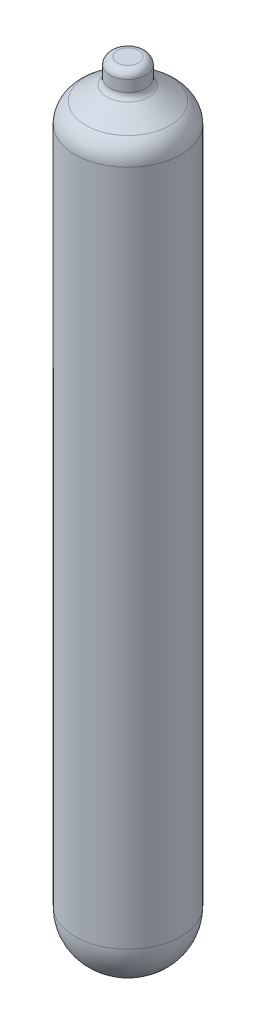
from build123d import *


with BuildPart() as part:
    # Эскиз1 → Повернуть1 (revolve)
    with BuildSketch(Plane.XY):
        with BuildLine():
            Line((0, 0), (10, 0))
            ThreePointArc((10, 0), (80.710678119, 29.289321881), (110, 100))
            Line((110, 100), (110, 1507.617384372))
            ThreePointArc((110, 1507.617384372), (104.090062317, 1531.198444671), (87.757343806, 1549.205001097))
            Line((87.757343806, 1549.205001097), (43.961595612, 1578.436145741))
            ThreePointArc((43.961595612, 1578.436145741), (39.061780059, 1583.838112668), (37.288798754, 1590.912430758))
            Line((37.288798754, 1590.912430758), (37.288798754, 1614.158761672))
            ThreePointArc((37.288798754, 1614.158761672), (32.895400472, 1624.76536339), (22.288798754, 1629.158761672))
            Line((22.288798754, 1629.158761672), (0, 1629.158761672))
            Line((0, 1629.158761672), (0, 0))
        make_face()
    revolve(axis=Axis((0, 1553.075867376, 0), (0, -1, 0)))


solid = part.part
